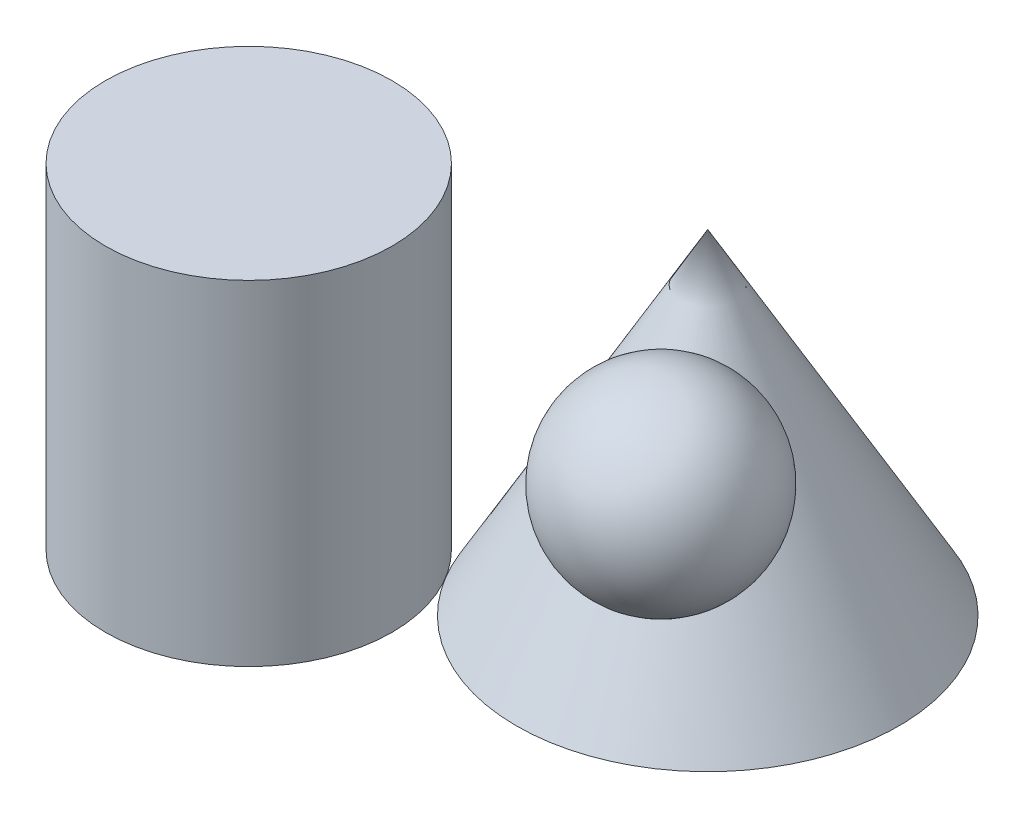
from build123d import *

# Parameters (mm, degrees)
SKETCH1_R      = 30
EXTRUDE1_DEPTH = 70


with BuildPart() as part:
    # Sketch2 → Revolve1 (revolve)
    with BuildSketch(Plane.XY, mode=Mode.PRIVATE) as revolve1_sk:
        Polygon((40, 0), (0, 0), (0, 70), align=None)
    revolve(revolve1_sk.sketch.rotate(Axis((0, 0, 0), (0, 1, 0)), 90), axis=Axis((0, 0, 0), (0, 1, 0)))  # turned: the seam where the file's is


with BuildPart() as body_2:
    # Sketch1 → Extrude1 (new body)
    with BuildSketch(Plane(origin=(0, 0, 0), x_dir=(1, 0, 0), z_dir=(0, 1, 0))):
        with Locations(Location((-60, -36.055512755, 0), (0, 0, 270))):  # turned: the seam where the file's is
            Circle(SKETCH1_R)
    extrude(amount=EXTRUDE1_DEPTH)


with BuildPart() as body_3:
    # Sketch6 → Revolve2 (revolve)
    with BuildSketch(Plane(origin=(0, 0, 0), x_dir=(0.554700196, 0, 0.832050294), z_dir=(-0.832050294, 0, 0.554700196))):
        with BuildLine():
            Line((35.39261922, 68.374205107), (35.39261922, 28.374205107))
            ThreePointArc((35.39261922, 28.374205107), (15.39261922, 48.374205107), (35.39261922, 68.374205107))
        make_face()
    revolve(axis=Axis((19.632292826, 68.374205107, 29.448439239), (0, -1, 0)))


solid = Compound([part.part, body_2.part, body_3.part])
